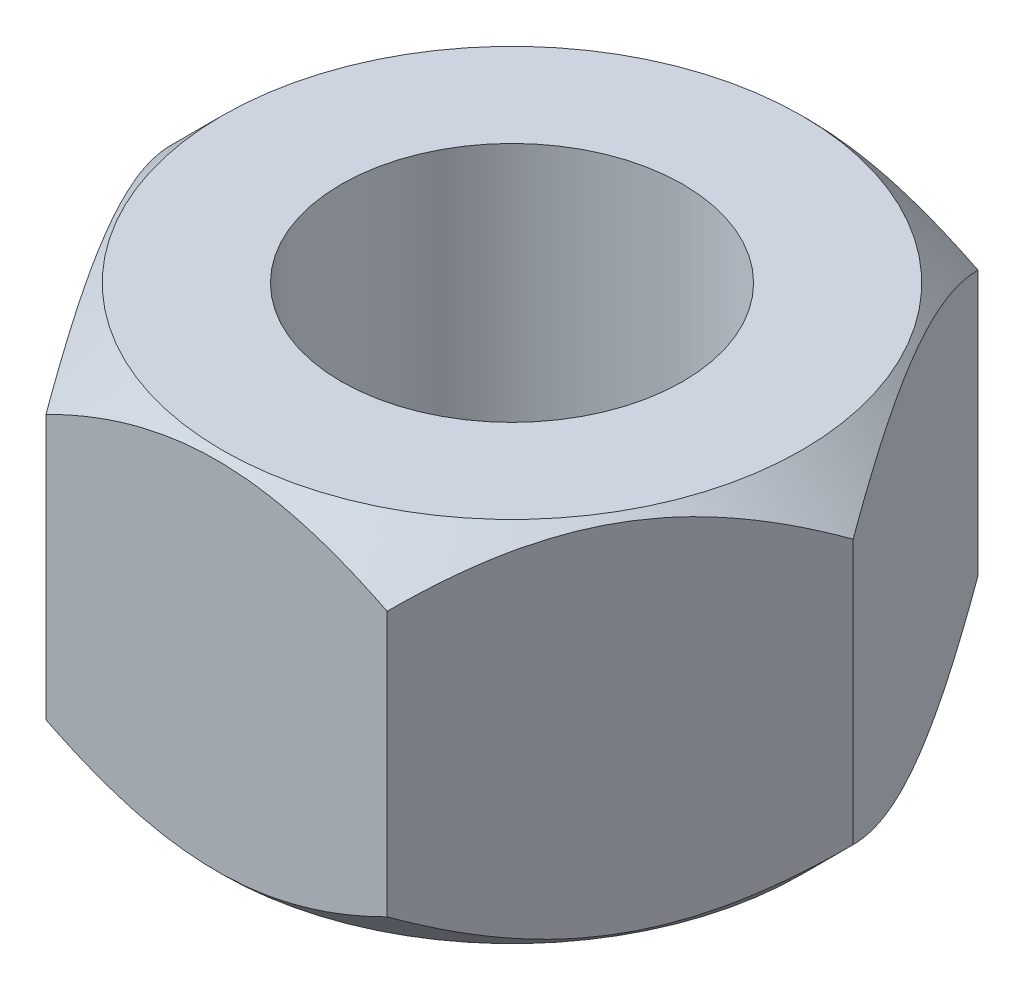
from build123d import *

# Parameters (mm, degrees)
CROQUIS1_R              = 6.65
SALIENTE_EXTRUIR1_DEPTH = 7.15


with BuildPart() as part:
    # Croquis1 → Saliente-Extruir1 (new body, symmetric)
    with BuildSketch(Plane(origin=(0, 0, 0), x_dir=(1, 0, 0), z_dir=(0, 1, 0))):
        Polygon((13.279056191, 0), (6.639528096, 11.5), (-6.639528096, 11.5), (-13.279056191, 0), (-6.639528096, -11.5), (6.639528096, -11.5), align=None)
        Circle(CROQUIS1_R, mode=Mode.SUBTRACT)
    extrude(amount=SALIENTE_EXTRUIR1_DEPTH, both=True)

    # Croquis2 → Cortar-Revolución1 (revolve, cut)
    with BuildSketch(Plane.XY):
        Polygon((-11.279056191, 7.15), (-13.279056191, 5.15), (-13.279056191, 7.15), align=None)
    cortar_revoluci_n1 = revolve(axis=Axis((0, 7.15, 0), (0, 1, 0)), mode=Mode.SUBTRACT)

    # Simetría1: Cortar-Revolución1 across plane
    add(cortar_revoluci_n1.mirror(Plane.ZX), mode=Mode.SUBTRACT)


solid = part.part
